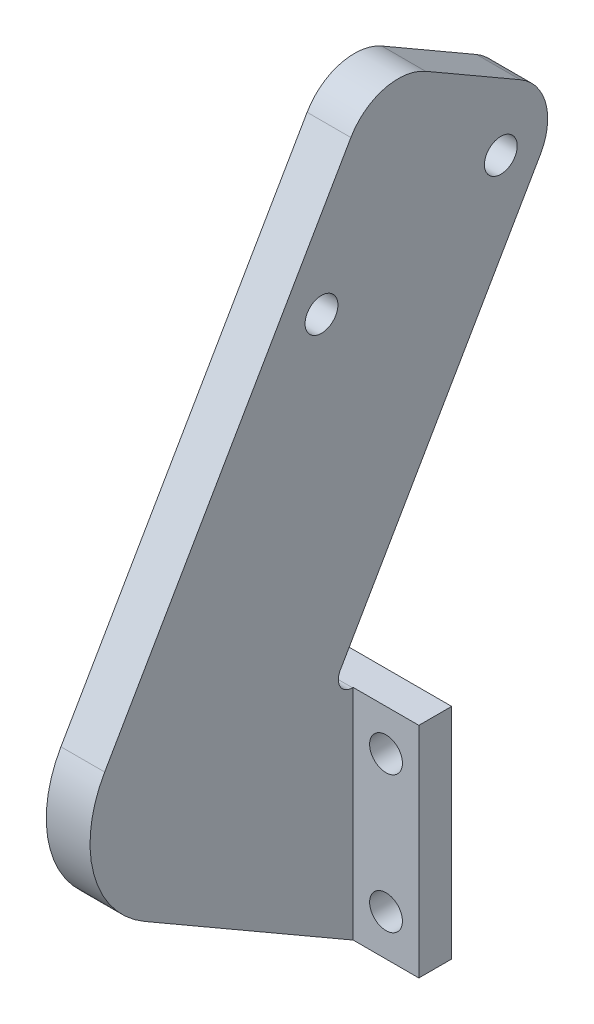
from build123d import *

# Parameters (mm, degrees)
SKETCH_1_W          = 17
SKETCH_1_H          = 20
SKETCH_1_R          = 1.5
EXTRUDE_1_DEPTH     = 3
EXTRUDE_2_DEPTH     = 5
SKETCH_4_R          = 1.5
CUT_EXTRUDE_1_DEPTH = 5
FILLET_2_R          = 5
FILLET_3_R          = 1.3
FILLET_4_R          = 10
SKETCH_5_W          = 6
SKETCH_5_H          = 20
CUT_EXTRUDE_2_DEPTH = 10
SKETCH_6_R          = 1.5
CUT_EXTRUDE_3_DEPTH = 1


with BuildPart() as part:
    # 草图1 → 凸台-拉伸1 (new body)
    with BuildSketch(Plane.XY):
        with Locations((8.5, 10)):
            Rectangle(SKETCH_1_W, SKETCH_1_H)
        with Locations((3, 16.25)):
            Circle(SKETCH_1_R, mode=Mode.SUBTRACT)
        with Locations((14, 16.25)):
            Circle(SKETCH_1_R, mode=Mode.SUBTRACT)
        with Locations((14, 3.75)):
            Circle(SKETCH_1_R, mode=Mode.SUBTRACT)
        with Locations((3, 3.75)):
            Circle(SKETCH_1_R, mode=Mode.SUBTRACT)
    extrude(amount=EXTRUDE_1_DEPTH)

    # 草图3 → 凸台-拉伸2 (add)
    with BuildSketch(Plane.ZY.offset(-6)):
        Polygon((3, 20), (5.309401077, 20), (-16.607695155, 57.961524227), (0.712812921, 67.961524227), (30.712812921, 16), (3, 0), align=None)
    extrude(amount=-EXTRUDE_2_DEPTH)

    # 草图4 → 切除-拉伸1 (cut)
    with BuildSketch(Plane(origin=(11, 0, 0), x_dir=(0, 0, -1), z_dir=(1, 0, 0))):
        with Locations((-5.898711306, 50.979284742)):
            Circle(SKETCH_4_R)
        with Locations((10.493593539, 55.371589587)):
            Circle(SKETCH_4_R)
    extrude(amount=-CUT_EXTRUDE_1_DEPTH, mode=Mode.SUBTRACT)

    # 圆角2
    fillet_2_edges = [part.edges().sort_by_distance(p)[0] for p in [
        (8.5, 57.961524227, -16.607695155),
        (8.5, 67.961524227, 0.712812921),
    ]]
    fillet(fillet_2_edges, radius=FILLET_2_R)

    # 圆角3
    fillet_3_edges = [part.edges().sort_by_distance(p)[0] for p in [
        (8.5, 20, 5.309401077),
    ]]
    fillet(fillet_3_edges, radius=FILLET_3_R)

    # 圆角4
    fillet_4_edges = [part.edges().sort_by_distance(p)[0] for p in [
        (8.5, 16, 30.712812921),
    ]]
    fillet(fillet_4_edges, radius=FILLET_4_R)

    # 草图5 → 切除-拉伸2 (cut)
    with BuildSketch(Plane.XY.offset(3)):
        with Locations((3, 10)):
            Rectangle(SKETCH_5_W, SKETCH_5_H)
    extrude(amount=-CUT_EXTRUDE_2_DEPTH, mode=Mode.SUBTRACT)

    # 草图6 → 切除-拉伸3 (cut)
    with BuildSketch(Plane.ZY.offset(-6)):
        with BuildLine():
            Line((3, 0), (22.052558883, 11))
            ThreePointArc((22.052558883, 11), (26.711817146, 17.072063587), (25.712812921, 24.660254038))
            Line((25.712812921, 24.660254038), (3.212812921, 63.631397208))
            ThreePointArc((3.212812921, 63.631397208), (0.176781128, 65.96102634), (-3.617314098, 65.461524227))
            Line((-3.617314098, 65.461524227), (-12.277568136, 60.461524227))
            ThreePointArc((-12.277568136, 60.461524227), (-14.607197267, 57.425492434), (-14.107695155, 53.631397208))
            Line((-14.107695155, 53.631397208), (4.183568052, 21.95))
            ThreePointArc((4.183568052, 21.95), (4.183568052, 20.65), (3.057735027, 20))
            Line((3.057735027, 20), (0, 20))
            Line((0, 20), (0, 0))
            Line((0, 0), (3, 0))
        make_face()
        with Locations((5.898711306, 50.979284742)):
            Circle(SKETCH_6_R, mode=Mode.SUBTRACT)
        with Locations((-10.493593539, 55.371589587)):
            Circle(SKETCH_6_R, mode=Mode.SUBTRACT)
    extrude(amount=-CUT_EXTRUDE_3_DEPTH, mode=Mode.SUBTRACT)


solid = part.part
